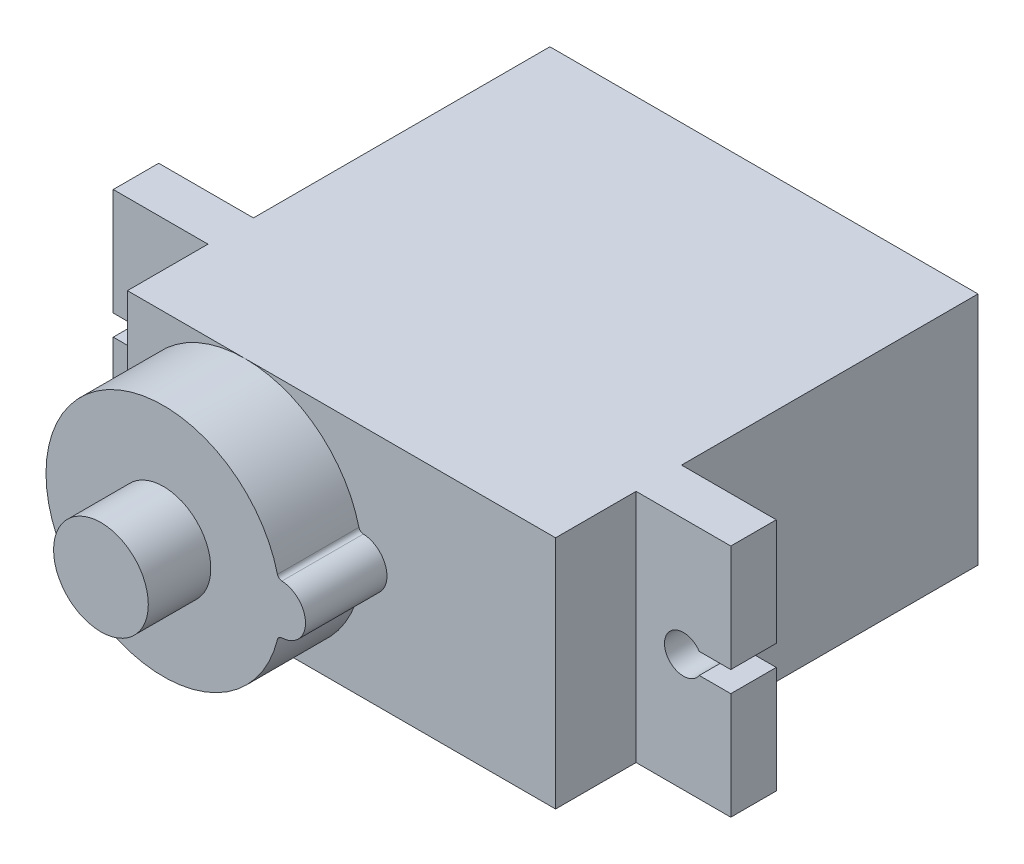
from build123d import *

# Parameters (mm, degrees)
SKETCH1_W             = 22.6
SKETCH1_H             = 12.4
BOSS_EXTRUDE1_DEPTH   = 22.3
SKETCH2_W             = 5
SKETCH2_H             = 2.4
BOSS_EXTRUDE2_DEPTH   = 12.4
CUT_EXTRUDE1_DEPTH    = 22.3
BOSS_EXTRUDE3_DEPTH   = 4.3
SKETCH6_R             = 2.5
BOSS_EXTRUDE4_DEPTH   = 3.3
SKETCH7_R             = 0.6
BOSS_EXTRUDE5_DEPTH   = 3.3
BOSS_EXTRUDE5_2_DEPTH = 3.3
BOSS_EXTRUDE5_3_DEPTH = 3.3


with BuildPart() as part:
    # Sketch1 → Boss-Extrude1 (new body)
    with BuildSketch(Plane.XY):
        Rectangle(SKETCH1_W, SKETCH1_H)
    extrude(amount=BOSS_EXTRUDE1_DEPTH)

    # Sketch2 → Boss-Extrude2 (add)
    with BuildSketch(Plane.XZ.offset(6.2)):
        with Locations((13.8, 16.85)):
            Rectangle(SKETCH2_W, SKETCH2_H)
        with Locations((-13.8, 16.85)):
            Rectangle(SKETCH2_W, SKETCH2_H)
    extrude(amount=-BOSS_EXTRUDE2_DEPTH)

    # Sketch3 → Cut-Extrude1 (cut)
    with BuildSketch(Plane.XY.offset(18.05)):
        with BuildLine():
            Line((14.635164654, 0.55), (16.3, 0.55))
            Line((16.3, 0.55), (16.3, -0.55))
            Line((16.3, -0.55), (14.635164654, -0.55))
            ThreePointArc((14.635164654, -0.55), (12.8, 0), (14.635164654, 0.55))
        make_face()
        with BuildLine():
            Line((-16.3, -0.55), (-14.635164654, -0.55))
            ThreePointArc((-14.635164654, -0.55), (-12.8, 0), (-14.635164654, 0.55))
            Line((-14.635164654, 0.55), (-16.3, 0.55))
            Line((-16.3, 0.55), (-16.3, -0.55))
        make_face()
    extrude(amount=-CUT_EXTRUDE1_DEPTH, mode=Mode.SUBTRACT)

    # Sketch4 → Boss-Extrude3 (add)
    with BuildSketch(Plane.XY.offset(22.3)):
        with BuildLine():
            ThreePointArc((0.918604651, 1.488757218), (-11.3, 0), (0.918604651, -1.488757218))
            ThreePointArc((0.918604651, -1.488757218), (1.003329596, -1.355013632), (1.151404787, -1.298983275))
            ThreePointArc((1.151404787, -1.298983275), (2.4, 0), (1.151404787, 1.298983275))
            ThreePointArc((1.151404787, 1.298983275), (1.003329596, 1.355013632), (0.918604651, 1.488757218))
        make_face()
    extrude(amount=BOSS_EXTRUDE3_DEPTH)

    # Sketch6 → Boss-Extrude4 (add)
    with BuildSketch(Plane.XY.offset(26.6)):
        with Locations((-5.1, 0)):
            Circle(SKETCH6_R)
    extrude(amount=BOSS_EXTRUDE4_DEPTH)


with BuildPart() as body_2:
    # Sketch7 → Boss-Extrude5 (new body)
    with BuildSketch(Plane.ZY.offset(11.3)):
        with Locations((4.5, 1.2)):
            Circle(SKETCH7_R)
    extrude(amount=BOSS_EXTRUDE5_DEPTH)


with BuildPart() as body_3:
    # Sketch7 → Boss-Extrude5 2 (new body)
    with BuildSketch(Plane.ZY.offset(11.3)):
        with Locations((4.5, 0)):
            Circle(SKETCH7_R)
    extrude(amount=BOSS_EXTRUDE5_2_DEPTH)


with BuildPart() as body_4:
    # Sketch7 → Boss-Extrude5 3 (new body)
    with BuildSketch(Plane.ZY.offset(11.3)):
        with Locations((4.5, -1.2)):
            Circle(SKETCH7_R)
    extrude(amount=BOSS_EXTRUDE5_3_DEPTH)


solid = Compound([part.part, body_2.part, body_3.part, body_4.part])
